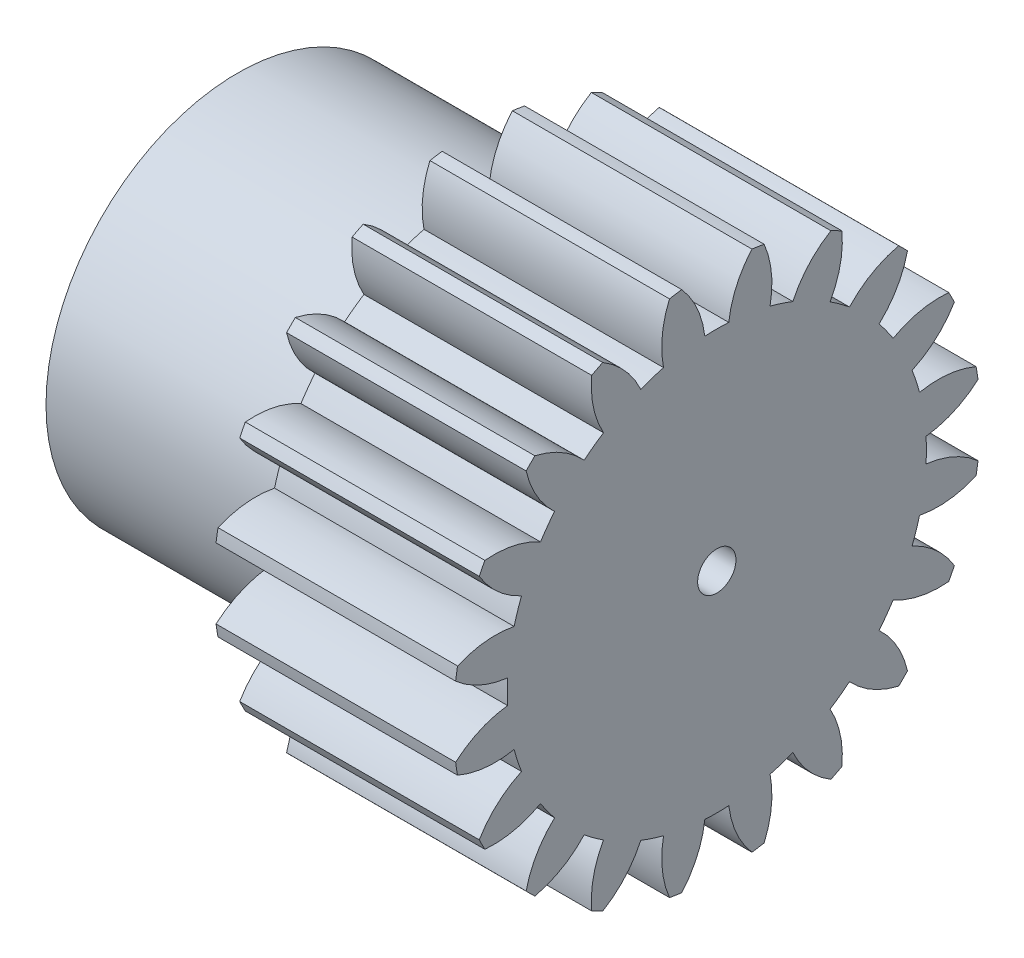
from build123d import *

# Parameters (mm, degrees)
BASPROSKE_W      = 5
BASPROSKE_H      = 5.5
TOOTHCUT_DEPTH   = 10.246621004
TEETHCUTS_COUNT  = 20
TEETHCUTS_ANGLE  = 342
HUBNEAONESKE_R   = 4
HUBNEARONE_DEPTH = 5.0000508
BORSKE_R         = 0.4
BORE_DEPTH       = 10.0000508


with BuildPart() as part:
    # BasProSke → Base-Revolve (revolve)
    with BuildSketch(Plane(origin=(0, 0, 0), x_dir=(1, 0, 0), z_dir=(0, 1, 0)), mode=Mode.PRIVATE) as base_revolve_sk:
        with Locations((2.5, 2.75)):
            Rectangle(BASPROSKE_W, BASPROSKE_H)
    revolve(base_revolve_sk.sketch.rotate(Axis((-10, 0, 0), (1, 0, 0)), 180), axis=Axis((-10, 0, 0), (1, 0, 0)))

    # TooCutSke → ToothCut (cut, through all)
    with BuildSketch(Plane(origin=(0, 0, 0), x_dir=(0, 0, -1), z_dir=(1, 0, 0))):
        with BuildLine():
            ThreePointArc((0.249903181, 4.366855207), (0, 4.374), (-0.249903181, 4.366855207))
            ThreePointArc((-0.249903181, 4.366855207), (-0.415207844, 4.95951031), (-0.752843848, 5.473871692))
            ThreePointArc((-0.752843848, 5.473871692), (0, 5.5254), (0.752843848, 5.473871692))
            ThreePointArc((0.752843848, 5.473871692), (0.415207844, 4.95951031), (0.249903181, 4.366855207))
        make_face()
    toothcut = extrude(amount=TOOTHCUT_DEPTH, mode=Mode.SUBTRACT)

    # TeethCuts: ToothCut ×20 about axis
    teethcuts_axis = Axis((-10, 0, 0), (1, 0, 0))
    for i in range(1, TEETHCUTS_COUNT):
        add(toothcut.rotate(teethcuts_axis, i * TEETHCUTS_ANGLE / (TEETHCUTS_COUNT - 1)), mode=Mode.SUBTRACT)

    # HubNeaOneSke → HubNearOne (add)
    with BuildSketch(Plane.ZY):
        with Locations(Location((0, 0, 0), (0, 0, 180))):
            Circle(HUBNEAONESKE_R)
    extrude(amount=HUBNEARONE_DEPTH)

    # BorSke → Bore (cut, symmetric)
    with BuildSketch(Plane(origin=(0, 0, 0), x_dir=(0, 0, -1), z_dir=(1, 0, 0))):
        with Locations(Location((0, 0, 0), (0, 0, 180))):
            Circle(BORSKE_R)
    extrude(amount=BORE_DEPTH, both=True, mode=Mode.SUBTRACT)


solid = part.part
